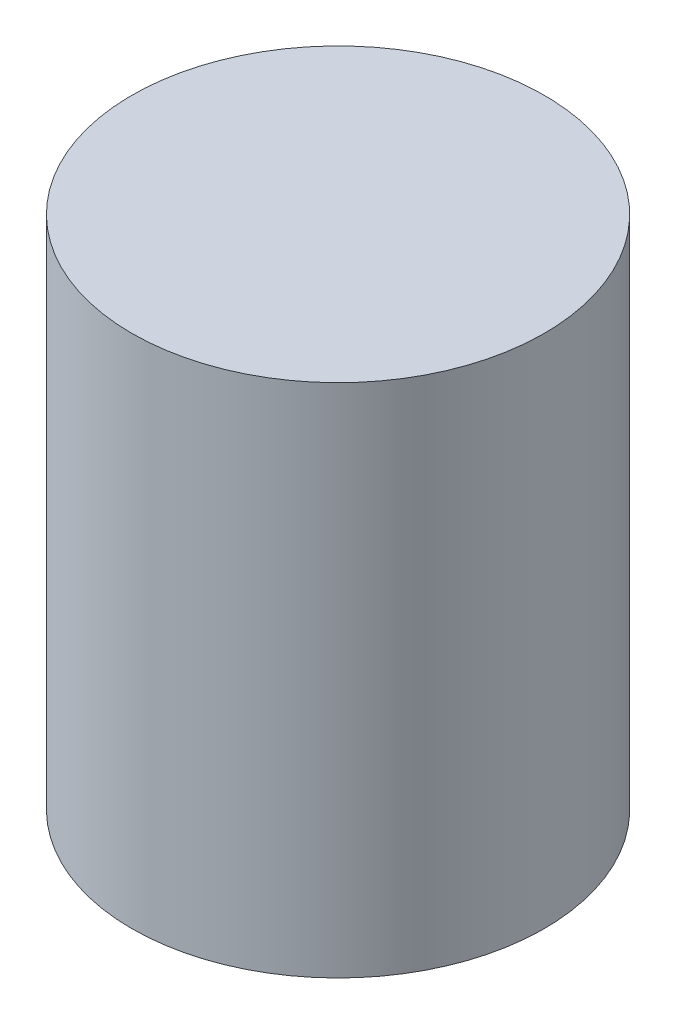
from build123d import *

# Parameters (mm, degrees)
SKETCH1_R           = 10
BOSS_EXTRUDE1_DEPTH = 25


with BuildPart() as part:
    # Sketch1 → Boss-Extrude1 (new body)
    with BuildSketch(Plane(origin=(0, 0, 0), x_dir=(1, 0, 0), z_dir=(0, 1, 0))):
        Circle(SKETCH1_R)
    extrude(amount=BOSS_EXTRUDE1_DEPTH)


solid = part.part
